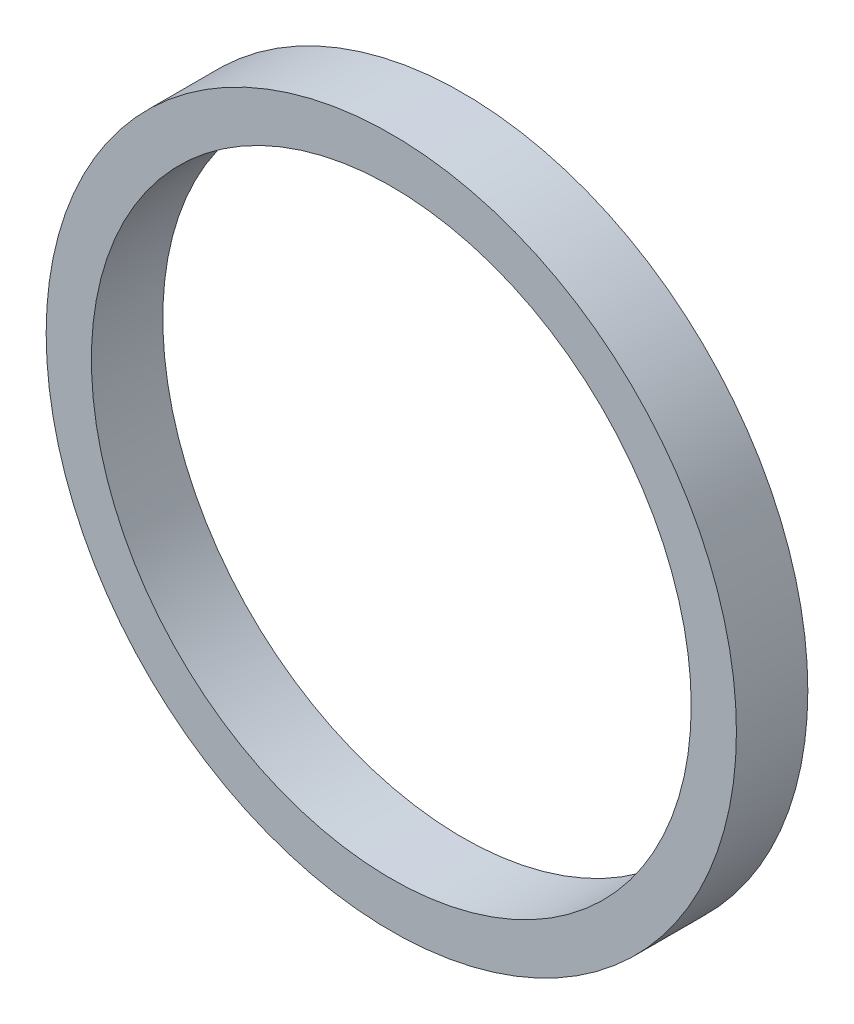
from build123d import *

# Parameters (mm, degrees)
ESQUISSE1_R        = 14.5
ESQUISSE1_R_2      = 12.6
BOSS_EXTRU_1_DEPTH = 3


with BuildPart() as part:
    # Esquisse1 → Boss.-Extru.1 (new body)
    with BuildSketch(Plane.XY):
        Circle(ESQUISSE1_R)
        Circle(ESQUISSE1_R_2, mode=Mode.SUBTRACT)
    extrude(amount=BOSS_EXTRU_1_DEPTH)


solid = part.part
